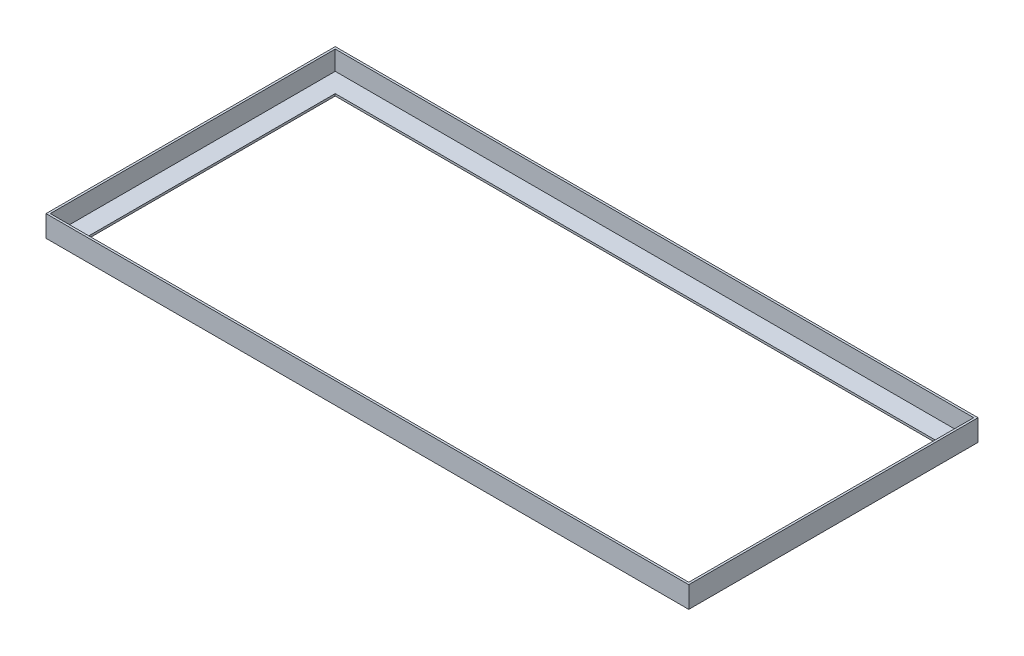
from build123d import *

# Parameters (mm, degrees)
SKETCH1_W           = 600
SKETCH1_H           = 20
BOSS_EXTRUDE1_DEPTH = 270
CUT_EXTRUDE1_DEPTH  = 18
CUT_EXTRUDE2_DEPTH  = 2


with BuildPart() as part:
    # Sketch1 → Boss-Extrude1 (new body)
    with BuildSketch(Plane.XY):
        with Locations((221.099899989, 5.665003505)):
            Rectangle(SKETCH1_W, SKETCH1_H)
    extrude(amount=-BOSS_EXTRUDE1_DEPTH)

    # 3DSketch1 → Cut-Extrude1 (cut)
    with BuildSketch(Plane(origin=(519.099899989, 15.665003505, -268), x_dir=(-0.9131786164814929, 0, 0.4075595838659012), z_dir=(0, 1, 0))):
        Polygon((0, 0), (544.254455423, -242.905511984), (652.665304731, 0), (108.410849308, 242.905511984), align=None)
    extrude(amount=-CUT_EXTRUDE1_DEPTH, mode=Mode.SUBTRACT)

    # 3DSketch2 → Cut-Extrude2 (cut)
    with BuildSketch(Plane(origin=(-58.900100011, -2.334996495, -250), x_dir=(0.9250198183784529, 0, 0.3799188539768646), z_dir=(0, 1, 0))):
        Polygon((0, 0), (518.011098292, 212.754558227), (605.392434707, 0), (87.381336415, -212.754558227), align=None)
    extrude(amount=-CUT_EXTRUDE2_DEPTH, mode=Mode.SUBTRACT)


solid = part.part
